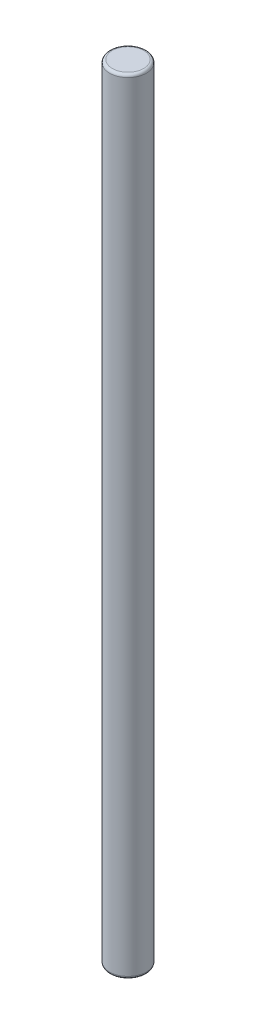
from build123d import *

# Parameters (mm, degrees)
SKETCH1_R           = 0.17145
BOSS_EXTRUDE1_DEPTH = 7.3152
FILLET1_R           = 0.0254


with BuildPart() as part:
    # Sketch1 → Boss-Extrude1 (new body)
    with BuildSketch(Plane(origin=(0, 0, 0), x_dir=(1, 0, 0), z_dir=(0, 1, 0))):
        Circle(SKETCH1_R)
    extrude(amount=BOSS_EXTRUDE1_DEPTH)

    # Fillet1
    fillet1_edges = [part.edges().sort_by_distance(p)[0] for p in [
        (-0.17145, 0, 0),
        (-0.17145, 7.3152, 0),
    ]]
    fillet(fillet1_edges, radius=FILLET1_R)


solid = part.part
